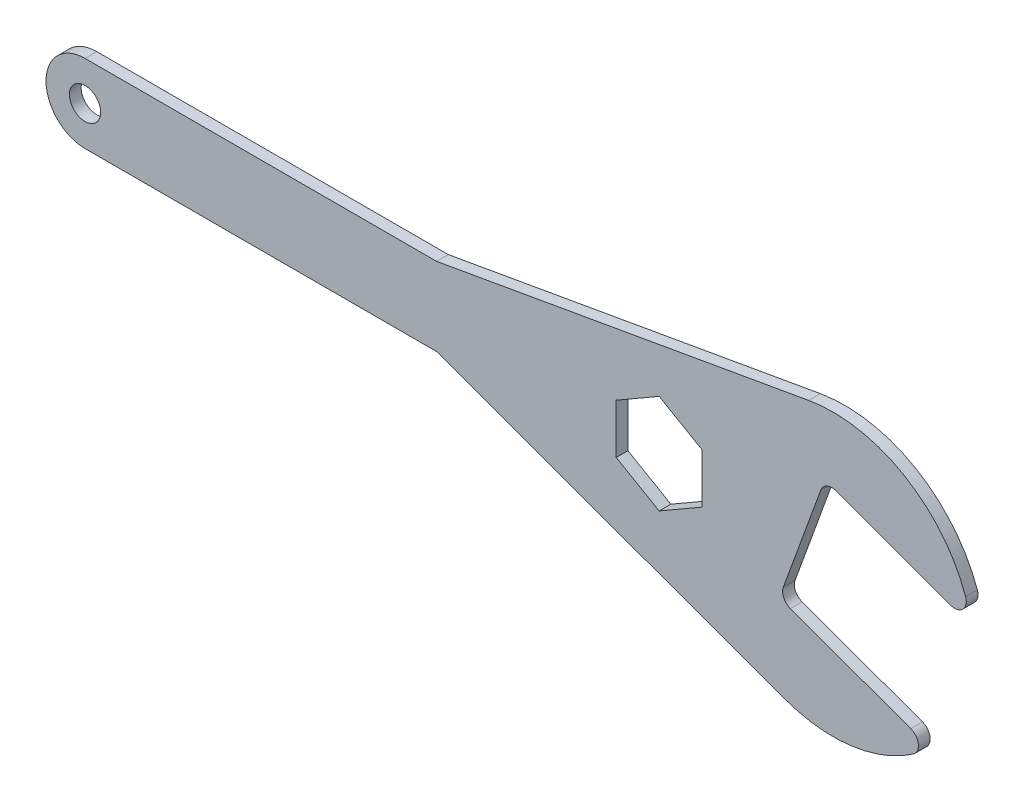
from build123d import *

# Parameters (mm, degrees)
BOSS_EXTRUDE1_DEPTH = 3
SKETCH3_R           = 4
CUT_EXTRUDE1_DEPTH  = 3
FILLET2_R           = 3
FILLET3_R           = 3
FILLET4_R           = 3
FILLET5_R           = 3


with BuildPart() as part:
    # Sketch2 → Boss-Extrude1 (new body)
    with BuildSketch(Plane.XY):
        with BuildLine():
            Line((0, 10), (90, 10))
            Line((90, 10), (185.282890453, 26.800944387))
            ThreePointArc((185.282890453, 26.800944387), (212.182976557, 20.837338873), (226.987303957, -2.400800326))
            Line((226.987303957, -2.400800326), (189.399599126, 11.280005407))
            Line((189.399599126, 11.280005407), (177.770914253, -20.669543699))
            Line((177.770914253, -20.669543699), (216.366079007, -34.717034857))
            ThreePointArc((216.366079007, -34.717034857), (198.899834433, -43.890576734), (179.221499689, -42.48106907))
            Line((179.221499689, -42.48106907), (89.98049586, -10))
            Line((89.98049586, -10), (0, -10))
            ThreePointArc((0, -10), (-10, 0), (0, 10))
        make_face()
    extrude(amount=BOSS_EXTRUDE1_DEPTH)

    # Sketch3 → Cut-Extrude1 (cut)
    with BuildSketch(Plane.XY.offset(3)):
        Circle(SKETCH3_R)
        Polygon((147, -16.85066389), (158, -10.499810929), (158, 2.201894993), (147, 8.552747954), (136, 2.201894993), (136, -10.499810929), align=None)
    extrude(amount=-CUT_EXTRUDE1_DEPTH, mode=Mode.SUBTRACT)

    # Fillet2
    fillet2_edges = [part.edges().sort_by_distance(p)[0] for p in [
        (216.366079007, -34.717034857, 1.5),
    ]]
    fillet(fillet2_edges, radius=FILLET2_R)

    # Fillet3
    fillet3_edges = [part.edges().sort_by_distance(p)[0] for p in [
        (226.987303957, -2.400800326, 1.5),
    ]]
    fillet(fillet3_edges, radius=FILLET3_R)

    # Fillet4
    fillet4_edges = [part.edges().sort_by_distance(p)[0] for p in [
        (177.770914253, -20.669543699, 1.5),
    ]]
    fillet(fillet4_edges, radius=FILLET4_R)

    # Fillet5
    fillet5_edges = [part.edges().sort_by_distance(p)[0] for p in [
        (189.399599126, 11.280005407, 1.5),
    ]]
    fillet(fillet5_edges, radius=FILLET5_R)


solid = part.part
